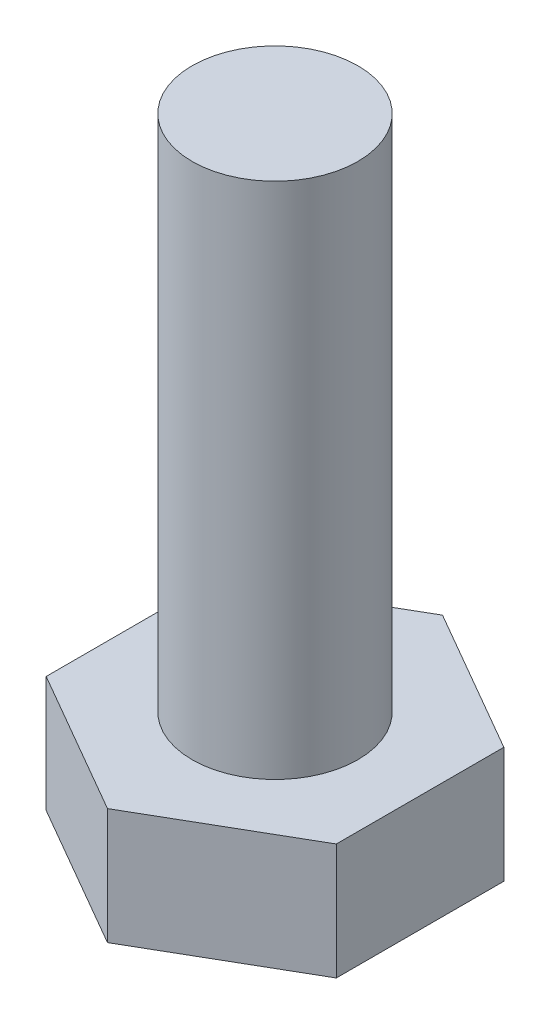
from build123d import *

# Parameters (mm, degrees)
BOSS_EXTRUDE1_DEPTH = 5.6
SKETCH2_R           = 4
BOSS_EXTRUDE2_DEPTH = 25


with BuildPart() as part:
    # Sketch1 → Boss-Extrude1 (new body)
    with BuildSketch(Plane(origin=(0, 0, 0), x_dir=(1, 0, 0), z_dir=(0, 1, 0))):
        Polygon((0, 8.082903769), (-7, 4.041451884), (-7, -4.041451884), (0, -8.082903769), (7, -4.041451884), (7, 4.041451884), align=None)
    extrude(amount=BOSS_EXTRUDE1_DEPTH)

    # Sketch2 → Boss-Extrude2 (add)
    with BuildSketch(Plane(origin=(0, 5.6, 0), x_dir=(1, 0, 0), z_dir=(0, 1, 0))):
        with Locations(Location((0, 0, 0), (0, 0, 270))):  # turned: the seam where the file's is
            Circle(SKETCH2_R)
    extrude(amount=BOSS_EXTRUDE2_DEPTH)


solid = part.part
